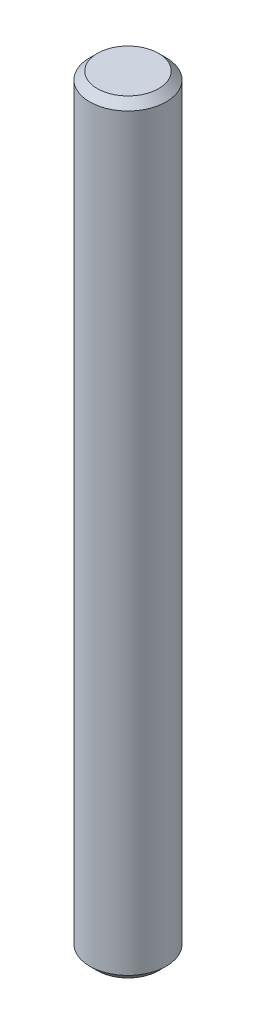
from build123d import *

# Parameters (mm, degrees)
SKETCH1_R           = 4.005
BOSS_EXTRUDE1_DEPTH = 80
CHAMFER1_SIZE       = 0.8


with BuildPart() as part:
    # Sketch1 → Boss-Extrude1 (new body)
    with BuildSketch(Plane(origin=(0, 0, 0), x_dir=(1, 0, 0), z_dir=(0, 1, 0))):
        Circle(SKETCH1_R)
    extrude(amount=BOSS_EXTRUDE1_DEPTH)

    # Chamfer1
    chamfer1_edges = [part.edges().sort_by_distance(p)[0] for p in [
        (-4.005, 0, 0),
        (-4.005, 80, 0),
    ]]
    chamfer(chamfer1_edges, length=CHAMFER1_SIZE)


solid = part.part
